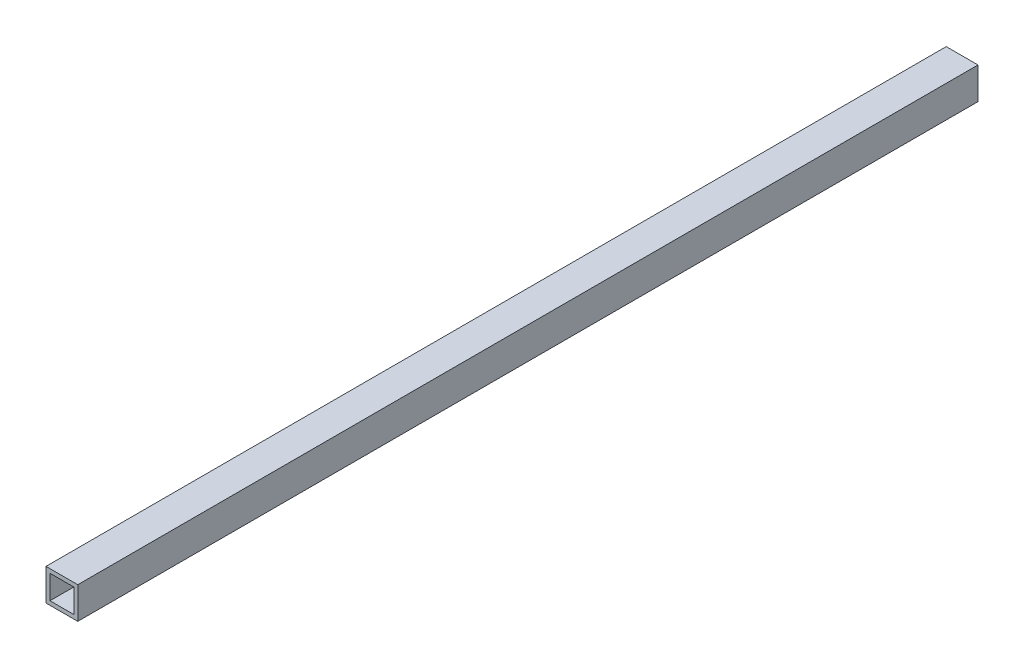
from build123d import *

# Parameters (mm, degrees)
SKETCH1_W           = 12
SKETCH1_H           = 12
SKETCH1_W_2         = 9
SKETCH1_H_2         = 9
BOSS_EXTRUDE1_DEPTH = 340


with BuildPart() as part:
    # Sketch1 → Boss-Extrude1 (new body)
    with BuildSketch(Plane.XY):
        with Locations((6, 6)):
            Rectangle(SKETCH1_W, SKETCH1_H)
        with Locations((6, 6)):
            Rectangle(SKETCH1_W_2, SKETCH1_H_2, mode=Mode.SUBTRACT)
    extrude(amount=BOSS_EXTRUDE1_DEPTH)


solid = part.part
